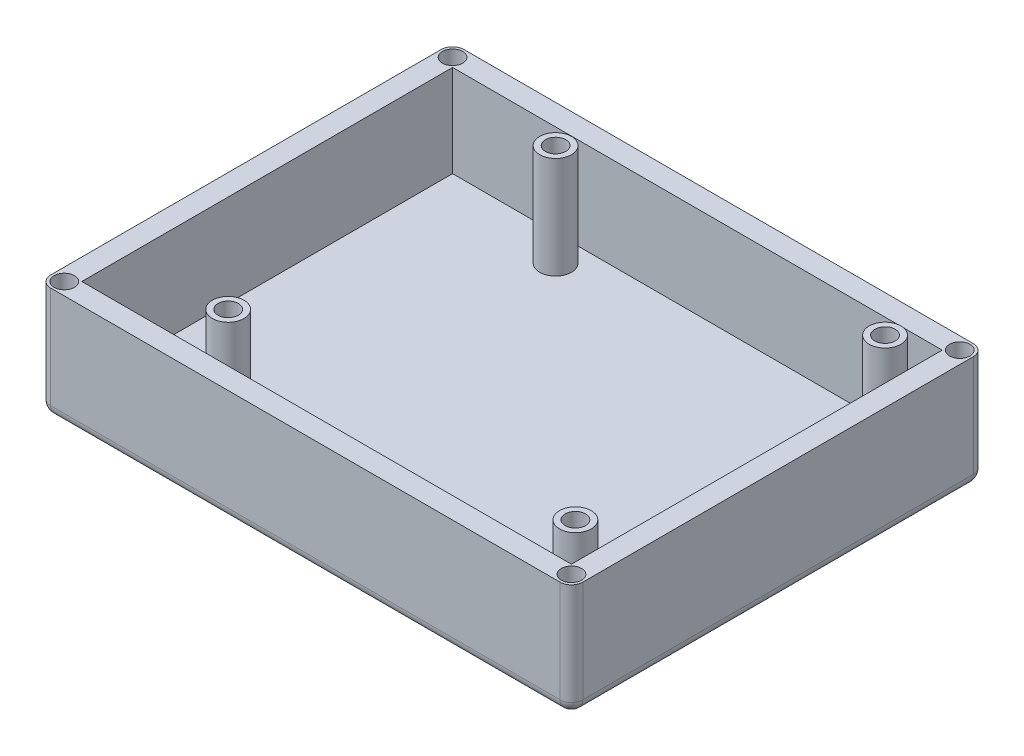
from build123d import *

# Parameters (mm, degrees)
SKETCH1_W           = 119.38
SKETCH1_H           = 25.4
BOSS_EXTRUDE1_DEPTH = 46.355
SKETCH2_W           = 109.855
SKETCH2_H           = 83.185
CUT_EXTRUDE1_DEPTH  = 20.6375
FILLET1_R           = 2.54
FILLET2_R           = 2.54
SKETCH8_R           = 2.286
CUT_EXTRUDE2_DEPTH  = 20.32
SKETCH16_R          = 2.286
CUT_EXTRUDE4_DEPTH  = 20.32
SKETCH17_R          = 2.286
CUT_EXTRUDE5_DEPTH  = 20.32
SKETCH18_R          = 2.286
CUT_EXTRUDE6_DEPTH  = 20.32
SKETCH9_R           = 3.556
SKETCH9_R_2         = 2.286
BOSS_EXTRUDE2_DEPTH = 22.86
SKETCH11_R          = 3.556
SKETCH11_R_2        = 2.286
BOSS_EXTRUDE3_DEPTH = 22.86
SKETCH12_R          = 3.556
SKETCH12_R_2        = 2.286
BOSS_EXTRUDE4_DEPTH = 22.86
SKETCH13_R          = 3.556
SKETCH13_R_2        = 2.286
BOSS_EXTRUDE5_DEPTH = 22.86


with BuildPart() as part:
    # Sketch1 → Boss-Extrude1 (new body, symmetric)
    with BuildSketch(Plane.XY):
        with Locations((0, 12.7)):
            Rectangle(SKETCH1_W, SKETCH1_H)
    extrude(amount=BOSS_EXTRUDE1_DEPTH, both=True)

    # Sketch2 → Cut-Extrude1 (cut)
    with BuildSketch(Plane(origin=(0, 25.4, 0), x_dir=(1, 0, 0), z_dir=(0, 1, 0))):
        Rectangle(SKETCH2_W, SKETCH2_H)
    extrude(amount=-CUT_EXTRUDE1_DEPTH, mode=Mode.SUBTRACT)

    # Fillet1
    fillet1_edges = [part.edges().sort_by_distance(p)[0] for p in [
        (59.69, 12.7, 46.355),
        (-59.69, 12.7, 46.355),
        (59.69, 12.7, -46.355),
        (-59.69, 12.7, -46.355),
    ]]
    fillet(fillet1_edges, radius=FILLET1_R)

    # Fillet2
    fillet2_edges = [part.edges().sort_by_distance(p)[0] for p in [
        (59.69, 0, 0),
        (0, 0, -46.355),
        (0, 0, 46.355),
        (-59.69, 0, 0),
        (58.946051224, 0, 45.611051224),
        (-58.946051224, 0, 45.611051224),
        (-58.946051224, 0, -45.611051224),
        (58.946051224, 0, -45.611051224),
    ]]
    fillet(fillet2_edges, radius=FILLET2_R)

    # Sketch8 → Cut-Extrude2 (cut)
    with BuildSketch(Plane(origin=(0, 25.4, 0), x_dir=(1, 0, 0), z_dir=(0, 1, 0))):
        with Locations((56.896, 43.561)):
            Circle(SKETCH8_R)
    extrude(amount=-CUT_EXTRUDE2_DEPTH, mode=Mode.SUBTRACT)

    # Sketch16 → Cut-Extrude4 (cut)
    with BuildSketch(Plane(origin=(0, 25.4, 0), x_dir=(1, 0, 0), z_dir=(0, 1, 0))):
        with Locations((-56.896, -43.561)):
            Circle(SKETCH16_R)
    extrude(amount=-CUT_EXTRUDE4_DEPTH, mode=Mode.SUBTRACT)

    # Sketch17 → Cut-Extrude5 (cut)
    with BuildSketch(Plane(origin=(0, 25.4, 0), x_dir=(1, 0, 0), z_dir=(0, 1, 0))):
        with Locations((56.896, -43.561)):
            Circle(SKETCH17_R)
    extrude(amount=-CUT_EXTRUDE5_DEPTH, mode=Mode.SUBTRACT)

    # Sketch18 → Cut-Extrude6 (cut)
    with BuildSketch(Plane(origin=(0, 25.4, 0), x_dir=(1, 0, 0), z_dir=(0, 1, 0))):
        with Locations((-56.896, 43.561)):
            Circle(SKETCH18_R)
    extrude(amount=-CUT_EXTRUDE6_DEPTH, mode=Mode.SUBTRACT)

    # Sketch9 → Boss-Extrude2 (add)
    with BuildSketch(Plane(origin=(0, 4.7625, 0), x_dir=(1, 0, 0), z_dir=(0, 1, 0))):
        with Locations((-25.9715, 35.7505)):
            Circle(SKETCH9_R)
        with Locations((-25.9715, 35.7505)):
            Circle(SKETCH9_R_2, mode=Mode.SUBTRACT)
    extrude(amount=BOSS_EXTRUDE2_DEPTH)

    # Sketch11 → Boss-Extrude3 (add)
    with BuildSketch(Plane(origin=(0, 4.7625, 0), x_dir=(1, 0, 0), z_dir=(0, 1, 0))):
        with Locations((-30.8737, -32.8041)):
            Circle(SKETCH11_R)
        with Locations((-30.8737, -32.8041)):
            Circle(SKETCH11_R_2, mode=Mode.SUBTRACT)
    extrude(amount=BOSS_EXTRUDE3_DEPTH)

    # Sketch12 → Boss-Extrude4 (add)
    with BuildSketch(Plane(origin=(0, 4.7625, 0), x_dir=(1, 0, 0), z_dir=(0, 1, 0))):
        with Locations((47.8155, 35.8775)):
            Circle(SKETCH12_R)
        with Locations((47.8155, 35.8775)):
            Circle(SKETCH12_R_2, mode=Mode.SUBTRACT)
    extrude(amount=BOSS_EXTRUDE4_DEPTH)

    # Sketch13 → Boss-Extrude5 (add)
    with BuildSketch(Plane(origin=(0, 4.7625, 0), x_dir=(1, 0, 0), z_dir=(0, 1, 0))):
        with Locations((48.9585, -34.7345)):
            Circle(SKETCH13_R)
        with Locations((48.9585, -34.7345)):
            Circle(SKETCH13_R_2, mode=Mode.SUBTRACT)
    extrude(amount=BOSS_EXTRUDE5_DEPTH)


solid = part.part
